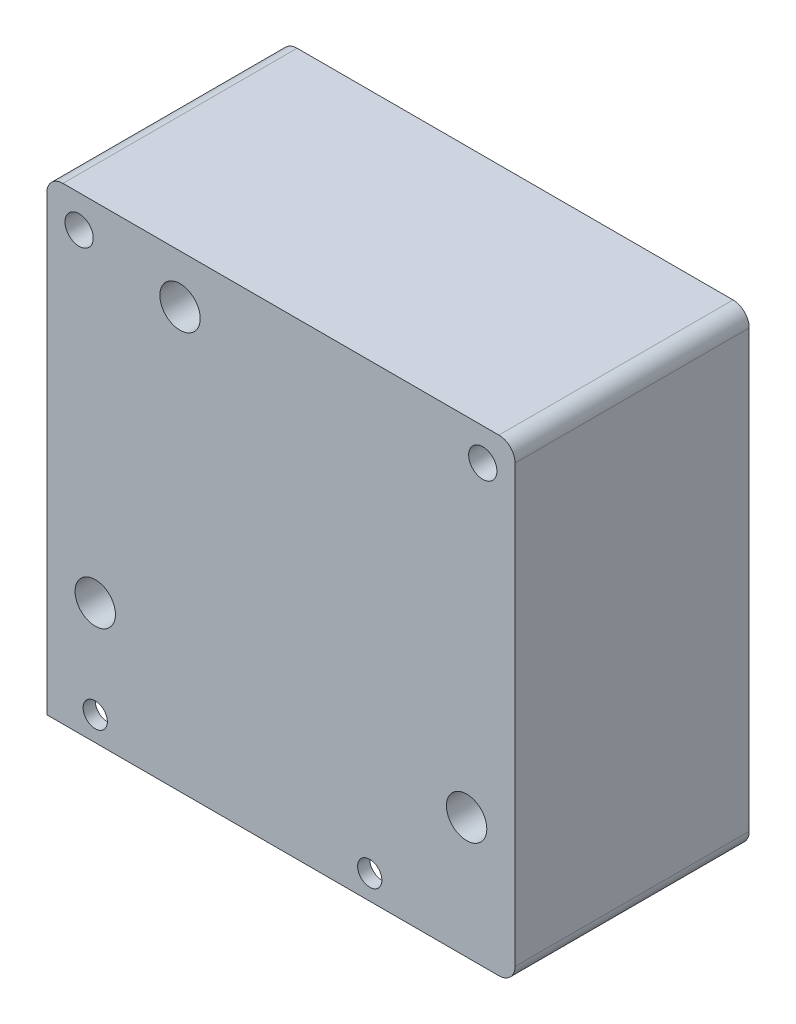
from build123d import *

# Parameters (mm, degrees)
SKETCH1_R           = 1.5
SKETCH1_R_2         = 2.5
SKETCH1_R_3         = 1.75
BOSS_EXTRUDE1_DEPTH = 29
SKETCH1_3_W         = 46.5
SKETCH1_3_H         = 6
SKETCH1_3_R         = 1.5
CUT_EXTRUDE1_DEPTH  = 27.5


with BuildPart() as part:
    # Sketch1 → Boss-Extrude1 (new body)
    with BuildSketch(Plane.XY):
        with BuildLine():
            Line((-29, -29), (27, -29))
            ThreePointArc((27, -29), (28.414213562, -28.414213562), (29, -27))
            Line((29, -27), (29, 27))
            ThreePointArc((29, 27), (28.414213562, 28.414213562), (27, 29))
            Line((27, 29), (-27, 29))
            ThreePointArc((-27, 29), (-28.414213562, 28.414213562), (-29, 27))
            Line((-29, 27), (-29, -29))
        make_face()
        with Locations((-23, -26)):
            Circle(SKETCH1_R, mode=Mode.SUBTRACT)
        with Locations((11, -26)):
            Circle(SKETCH1_R, mode=Mode.SUBTRACT)
        with Locations((-12.5, 23)):
            Circle(SKETCH1_R_2, mode=Mode.SUBTRACT)
        with Locations((25, 25)):
            Circle(SKETCH1_R_3, mode=Mode.SUBTRACT)
        with Locations((-23, -14)):
            Circle(SKETCH1_R_2, mode=Mode.SUBTRACT)
        with Locations((23, -14)):
            Circle(SKETCH1_R_2, mode=Mode.SUBTRACT)
        with Locations((-25, 25)):
            Circle(SKETCH1_R_3, mode=Mode.SUBTRACT)
    extrude(amount=BOSS_EXTRUDE1_DEPTH)

    # Sketch1_3 → Cut-Extrude1 (cut)
    with BuildSketch(Plane.XY):
        with Locations((-5.75, -26)):
            Rectangle(SKETCH1_3_W, SKETCH1_3_H)
        with Locations((-23, -26)):
            Circle(SKETCH1_3_R, mode=Mode.SUBTRACT)
        with Locations((11, -26)):
            Circle(SKETCH1_3_R, mode=Mode.SUBTRACT)
    extrude(amount=CUT_EXTRUDE1_DEPTH, mode=Mode.SUBTRACT)


solid = part.part
